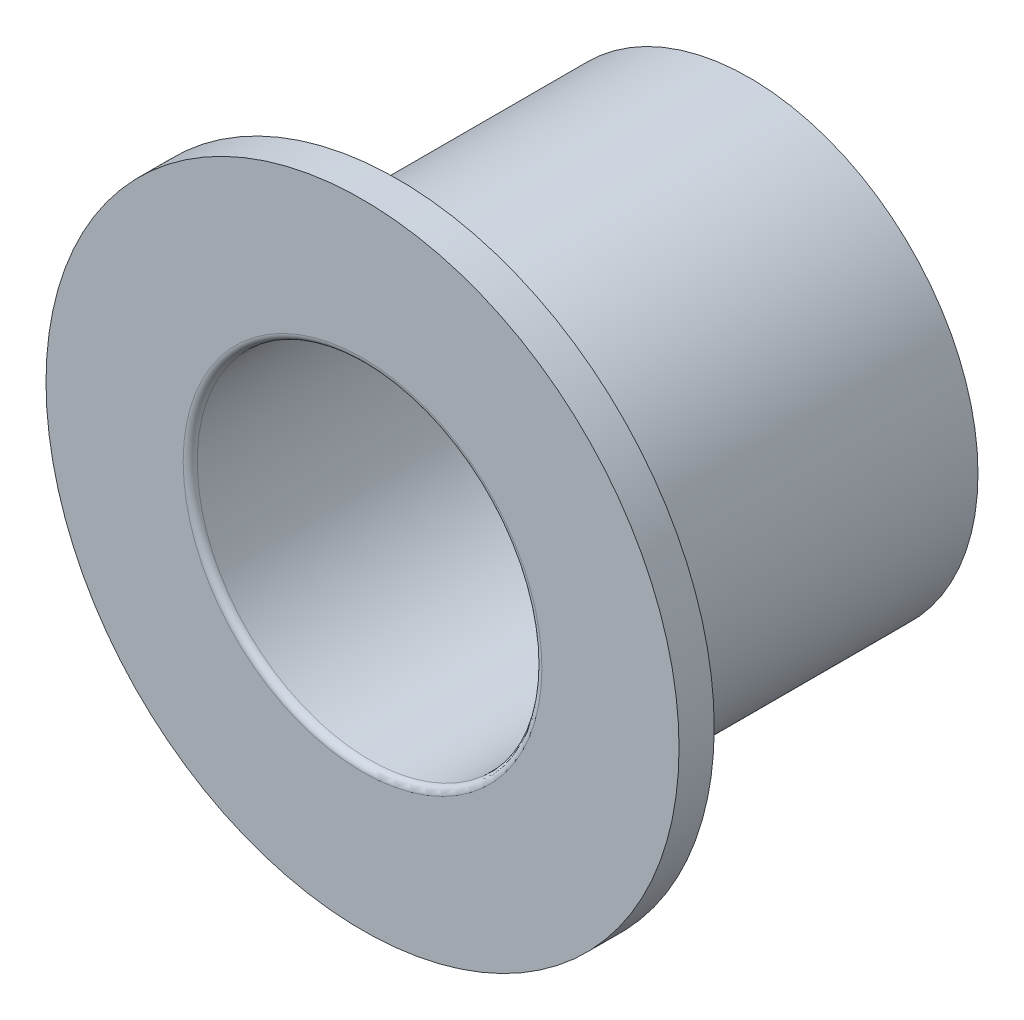
from build123d import *

# Parameters (mm, degrees)
SKETCH1_R               = 1.651
BOSS_EXTRUDE1_DEPTH     = 2.54
SKETCH2_R               = 2.286
BOSS_EXTRUDE2_DEPTH     = 0.254
SKETCH3_R               = 1.2446
CUT_EXTRUDE3_DEPTH      = 1
CUT_EXTRUDE3_DEPTH_BACK = 3.794
FILLET3_R               = 0.0508


with BuildPart() as part:
    # Sketch1 → Boss-Extrude1 (new body)
    with BuildSketch(Plane.XY):
        Circle(SKETCH1_R)
    extrude(amount=BOSS_EXTRUDE1_DEPTH)

    # Sketch2 → Boss-Extrude2 (add)
    with BuildSketch(Plane.XY.offset(2.54)):
        Circle(SKETCH2_R)
    extrude(amount=BOSS_EXTRUDE2_DEPTH)

    # Sketch3 → Cut-Extrude3 (cut, two sides)
    with BuildSketch(Plane(origin=(0, 0, 0), x_dir=(-1, 0, 0), z_dir=(0, 0, -1))) as cut_extrude3_sk:
        Circle(SKETCH3_R)
    extrude(amount=CUT_EXTRUDE3_DEPTH, mode=Mode.SUBTRACT)
    extrude(cut_extrude3_sk.sketch, amount=-CUT_EXTRUDE3_DEPTH_BACK, mode=Mode.SUBTRACT)

    # Fillet3
    fillet3_edges = [part.edges().sort_by_distance(p)[0] for p in [
        (1.2446, 0, 2.794),
    ]]
    fillet(fillet3_edges, radius=FILLET3_R)


solid = part.part
